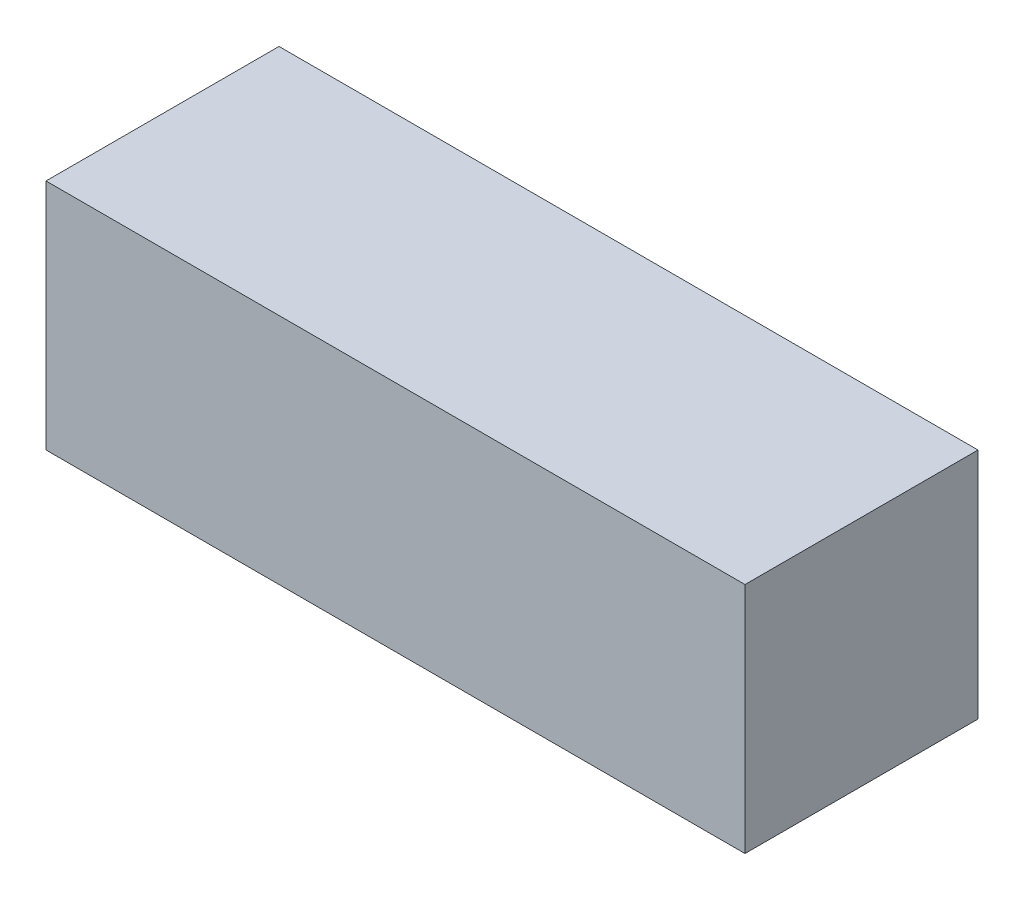
from build123d import *

# Parameters (mm, degrees)
SKETCH1_W           = 100
SKETCH1_H           = 100
BOSS_EXTRUDE1_DEPTH = 300


with BuildPart() as part:
    # Sketch1 → Boss-Extrude1 (new body)
    with BuildSketch(Plane(origin=(0, 0, 0), x_dir=(0, 0, -1), z_dir=(1, 0, 0))):
        with Locations((8.852872436, 17.82450358)):
            Rectangle(SKETCH1_W, SKETCH1_H)
    extrude(amount=BOSS_EXTRUDE1_DEPTH)


solid = part.part
